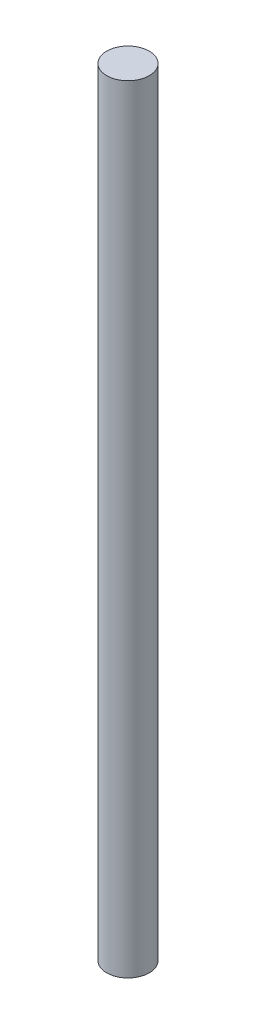
from build123d import *

# Parameters (mm, degrees)
SKETCH2_R           = 2
BOSS_EXTRUDE1_DEPTH = 73


with BuildPart() as part:
    # Sketch2 → Boss-Extrude1 (new body)
    with BuildSketch(Plane(origin=(0, 0, 0), x_dir=(1, 0, 0), z_dir=(0, 1, 0))):
        Circle(SKETCH2_R)
    extrude(amount=BOSS_EXTRUDE1_DEPTH)


solid = part.part
